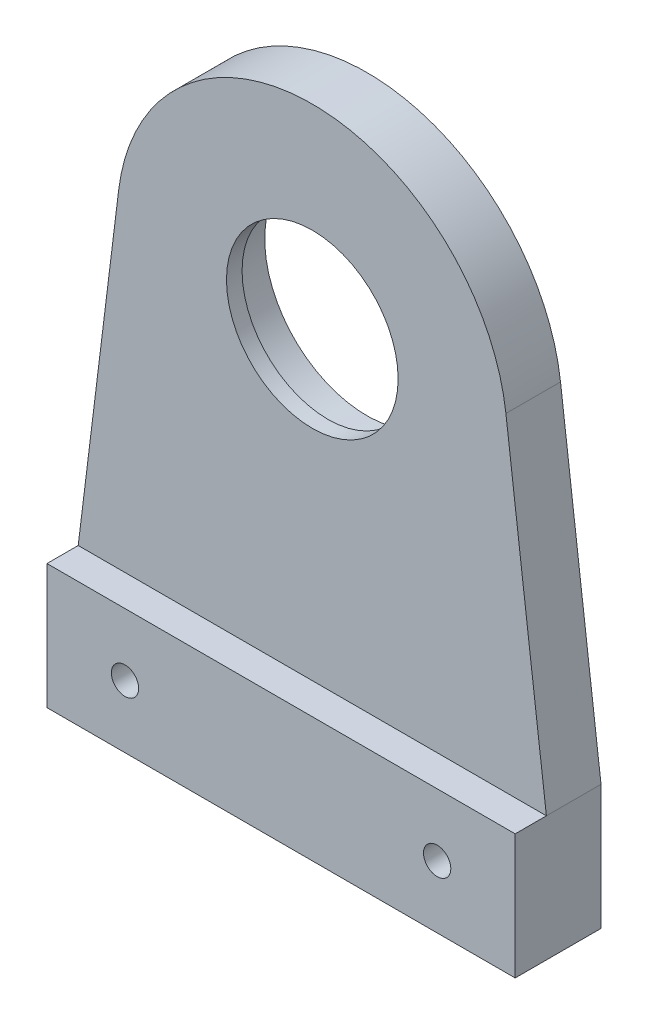
from build123d import *

# Parameters (mm, degrees)
SKETCH1_R           = 13.1
SKETCH1_R_2         = 1.75
BOSS_EXTRUDE1_DEPTH = 7
SKETCH2_R           = 13.1
SKETCH2_R_2         = 11
BOSS_EXTRUDE2_DEPTH = 2
SKETCH3_W           = 60
SKETCH3_H           = 16
SKETCH3_R           = 1.75
BOSS_EXTRUDE3_DEPTH = 4
SKETCH4_R           = 3.75
CUT_EXTRUDE1_DEPTH  = 4


with BuildPart() as part:
    # Sketch1 → Boss-Extrude1 (new body)
    with BuildSketch(Plane.XY):
        with BuildLine():
            Line((-30, -55), (30, -55))
            Line((30, -55), (30, -39))
            Line((30, -39), (24.811961667, 3.060483334))
            ThreePointArc((24.811961667, 3.060483334), (0, 25), (-24.811961667, 3.060483334))
            Line((-24.811961667, 3.060483334), (-30, -39))
            Line((-30, -39), (-30, -55))
        make_face()
        Circle(SKETCH1_R, mode=Mode.SUBTRACT)
        with Locations((-20, -47)):
            Circle(SKETCH1_R_2, mode=Mode.SUBTRACT)
        with Locations((20, -47)):
            Circle(SKETCH1_R_2, mode=Mode.SUBTRACT)
    extrude(amount=BOSS_EXTRUDE1_DEPTH)

    # Sketch2 → Boss-Extrude2 (add)
    with BuildSketch(Plane.XY.offset(7)):
        Circle(SKETCH2_R)
        Circle(SKETCH2_R_2, mode=Mode.SUBTRACT)
    extrude(amount=-BOSS_EXTRUDE2_DEPTH)

    # Sketch3 → Boss-Extrude3 (add)
    with BuildSketch(Plane.XY.offset(7)):
        with Locations((0, -47)):
            Rectangle(SKETCH3_W, SKETCH3_H)
        with Locations((20, -47)):
            Circle(SKETCH3_R, mode=Mode.SUBTRACT)
        with Locations((-20, -47)):
            Circle(SKETCH3_R, mode=Mode.SUBTRACT)
    extrude(amount=BOSS_EXTRUDE3_DEPTH)

    # Sketch4 → Cut-Extrude1 (cut)
    with BuildSketch(Plane(origin=(0, 0, 0), x_dir=(-1, 0, 0), z_dir=(0, 0, -1))):
        with Locations((-20, -47)):
            Circle(SKETCH4_R)
        with Locations((20, -47)):
            Circle(SKETCH4_R)
    extrude(amount=-CUT_EXTRUDE1_DEPTH, mode=Mode.SUBTRACT)


solid = part.part
